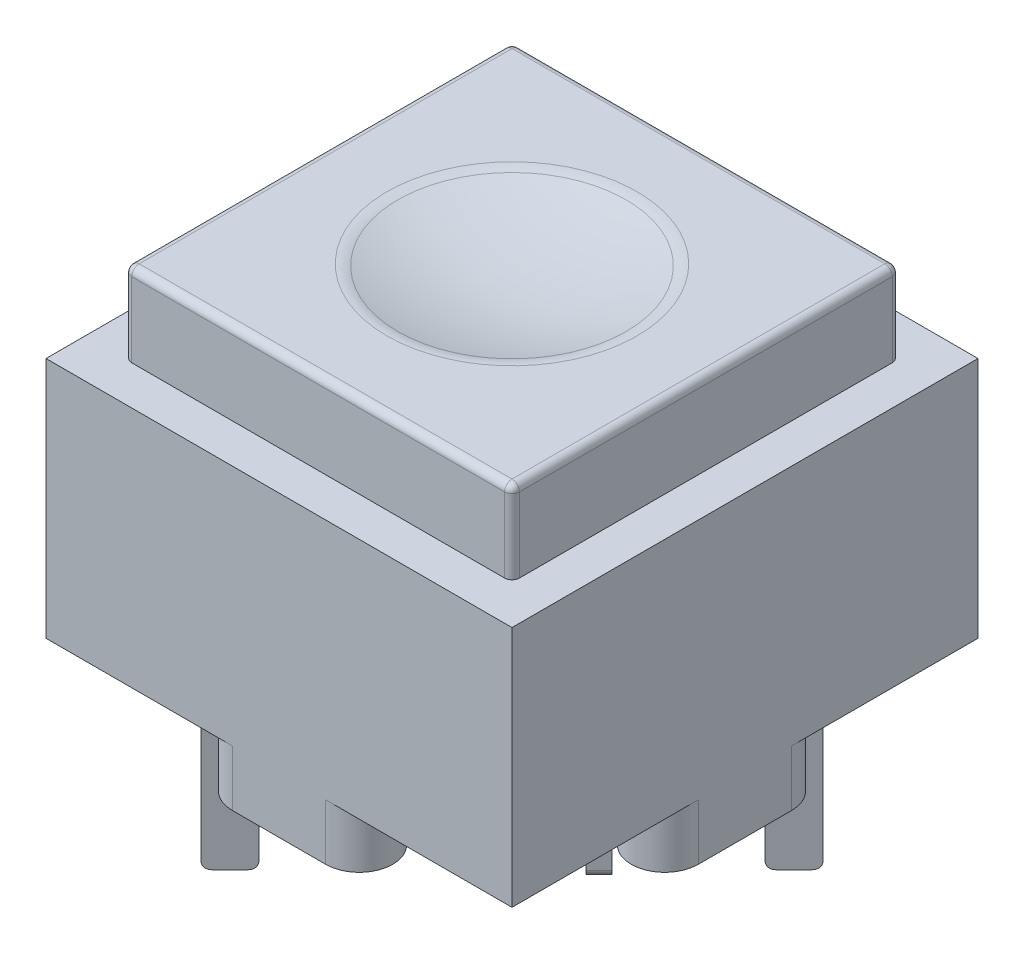
from build123d import *

# Parameters (mm, degrees)
SKETCH_1_W        = 12.5
SKETCH_1_H        = 12.5
EXTRUDE_1_DEPTH   = 6.5
SKETCH_2_R        = 0.85
EXTRUDE_2_DEPTH   = 1.5
EXTRUDE_3_DEPTH   = 5.2
EXTRUDE_3_2_DEPTH = 5.2
EXTRUDE_3_3_DEPTH = 5.2
FILLET_2_R        = 0.2
FILLET_3_R        = 0.2
FILLET_4_R        = 0.2
SKETCH_6_W        = 10.4
SKETCH_6_H        = 10.4
EXTRUDE_4_DEPTH   = 2.2
FILLET_5_R        = 0.2
FILLET_6_R        = 1


with BuildPart() as part:
    # Эскиз1 → Бобышка-Вытянуть1 (new body)
    with BuildSketch(Plane(origin=(0, 0, 0), x_dir=(1, 0, 0), z_dir=(0, 1, 0))):
        Rectangle(SKETCH_1_W, SKETCH_1_H)
    extrude(amount=EXTRUDE_1_DEPTH)

    # Эскиз2 → Бобышка-Вытянуть2 (add)
    with BuildSketch(Plane.XZ):
        with Locations((0, -5.35)):
            Circle(SKETCH_2_R)
        with BuildLine():
            Line((-1.251544725, 6.25), (1.251544725, 6.25))
            ThreePointArc((1.251544725, 6.25), (2.151544725, 5.35), (1.251544725, 4.45))
            Line((1.251544725, 4.45), (-1.251544725, 4.45))
            ThreePointArc((-1.251544725, 4.45), (-2.151544725, 5.35), (-1.251544725, 6.25))
        make_face()
        with BuildLine():
            Line((6.25, -1.251544725), (6.25, 1.251544725))
            ThreePointArc((6.25, 1.251544725), (5.35, 2.151544725), (4.45, 1.251544725))
            Line((4.45, 1.251544725), (4.45, -1.251544725))
            ThreePointArc((4.45, -1.251544725), (5.35, -2.151544725), (6.25, -1.251544725))
        make_face()
        with BuildLine():
            Line((-6.25, -1.251544725), (-6.25, 1.251544725))
            ThreePointArc((-6.25, 1.251544725), (-5.35, 2.151544725), (-4.45, 1.251544725))
            Line((-4.45, 1.251544725), (-4.45, -1.251544725))
            ThreePointArc((-4.45, -1.251544725), (-5.35, -2.151544725), (-6.25, -1.251544725))
        make_face()
    extrude(amount=EXTRUDE_2_DEPTH)


with BuildPart() as body_2:
    # Эскиз5 → Бобышка-Вытянуть3 (new body)
    with BuildSketch(Plane.XZ):
        Polygon((-3.995153314, 4.348706704), (-3.217335854, 3.570889245), (-3.570889245, 3.217335854), (-4.348706704, 3.995153314), align=None)
    extrude(amount=EXTRUDE_3_DEPTH)

    # Скругление2
    fillet_2_edges = [body_2.edges().sort_by_distance(p)[0] for p in [
        (-4.171930009, -5.2, 4.171930009),
        (-3.39411255, -5.2, 3.39411255),
    ]]
    fillet(fillet_2_edges, radius=FILLET_2_R)


with BuildPart() as body_3:
    # Эскиз5 → Extrude 3 2 (new body)
    with BuildSketch(Plane.XZ):
        Polygon((3.995153314, -4.348706704), (3.217335854, -3.570889245), (3.570889245, -3.217335854), (4.348706704, -3.995153314), align=None)
    extrude(amount=EXTRUDE_3_2_DEPTH)

    # Скругление4
    fillet_4_edges = [body_3.edges().sort_by_distance(p)[0] for p in [
        (3.39411255, -5.2, -3.39411255),
        (4.171930009, -5.2, -4.171930009),
    ]]
    fillet(fillet_4_edges, radius=FILLET_4_R)


with BuildPart() as body_4:
    # Эскиз5 → Extrude 3 3 (new body)
    with BuildSketch(Plane.XZ):
        Polygon((0.601040764, -1.378858223), (1.378858223, -0.601040764), (1.732411614, -0.954594155), (0.954594155, -1.732411614), align=None)
    extrude(amount=EXTRUDE_3_3_DEPTH)

    # Скругление3
    fillet_3_edges = [body_4.edges().sort_by_distance(p)[0] for p in [
        (0.777817459, -5.2, -1.555634919),
        (1.555634919, -5.2, -0.777817459),
    ]]
    fillet(fillet_3_edges, radius=FILLET_3_R)


with BuildPart() as body_5:
    # Эскиз6 → Бобышка-Вытянуть4 (new body)
    with BuildSketch(Plane(origin=(0, 6.5, 0), x_dir=(1, 0, 0), z_dir=(0, 1, 0))):
        Rectangle(SKETCH_6_W, SKETCH_6_H)
    extrude(amount=EXTRUDE_4_DEPTH)

    # Скругление5
    fillet_5_edges = [body_5.edges().sort_by_distance(p)[0] for p in [
        (-5.2, 8.7, 0),
        (0, 8.7, 5.2),
        (5.2, 8.7, 0),
        (0, 8.7, -5.2),
        (5.2, 7.6, 5.2),
        (-5.2, 7.6, 5.2),
        (-5.2, 7.6, -5.2),
        (5.2, 7.6, -5.2),
    ]]
    fillet(fillet_5_edges, radius=FILLET_5_R)

    # Эскиз7 → Вырез-Повернуть1 (revolve, cut)
    with BuildSketch(Plane.XY):
        with BuildLine():
            Line((0, 8.7), (3.2, 8.7))
            ThreePointArc((3.2, 8.7), (1.619413474, 8.325753766), (0, 8.2))
            Line((0, 8.2), (0, 8.7))
        make_face()
    revolve(axis=Axis((0, 8.2, 0), (0, 1, 0)), mode=Mode.SUBTRACT)

    # Скругление6
    fillet_6_edges = [body_5.edges().sort_by_distance(p)[0] for p in [
        (-3.2, 8.7, 0),
    ]]
    fillet(fillet_6_edges, radius=FILLET_6_R)


solid = Compound([part.part, body_2.part, body_3.part, body_4.part, body_5.part])
